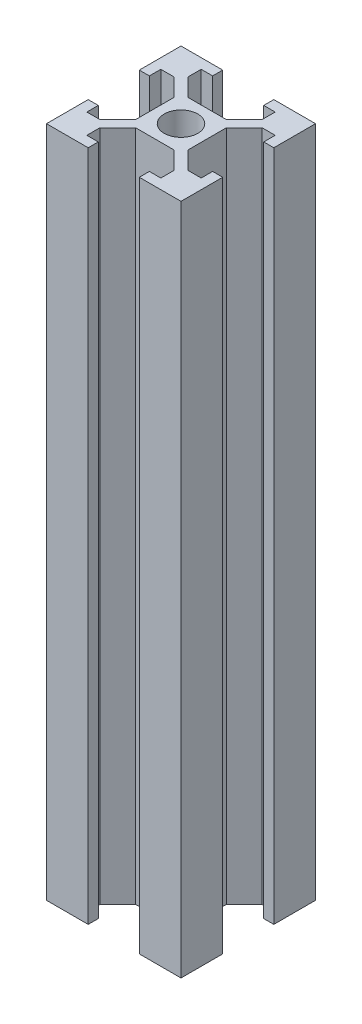
from build123d import *

# Parameters (mm, degrees)
SKETCH_1_W      = 1.5
SKETCH_1_H      = 1.7
SKETCH_1_W_2    = 1.7
SKETCH_1_H_2    = 1.5
SKETCH_1_W_3    = 7.8
SKETCH_1_H_3    = 7.8
SKETCH_1_R      = 2.5
EXTRUDE_1_DEPTH = 100


with BuildPart() as part:
    # 草图1 → 凸台-拉伸1 (new body)
    with BuildSketch(Plane(origin=(0, 0, 0), x_dir=(1, 0, 0), z_dir=(0, 1, 0))):
        Polygon((5.5, 8.5), (5.5, 6.560660172), (5.5, 5.5), (6.560660172, 5.5), (8.5, 5.5), (10, 5.5), (10, 10), (5.5, 10), align=None)
        with Locations((9.25, 4.65)):
            Rectangle(SKETCH_1_W, SKETCH_1_H)
        Polygon((5.5, 6.560660172), (2.839339828, 3.9), (3.9, 3.9), (3.9, 2.839339828), (6.560660172, 5.5), (5.5, 5.5), align=None)
        with Locations((4.65, 9.25)):
            Rectangle(SKETCH_1_W_2, SKETCH_1_H_2)
        Rectangle(SKETCH_1_W_3, SKETCH_1_H_3)
        Circle(SKETCH_1_R, mode=Mode.SUBTRACT)
        with Locations((-4.65, 9.25)):
            Rectangle(SKETCH_1_W_2, SKETCH_1_H_2)
        Polygon((-8.5, 5.5), (-6.560660172, 5.5), (-5.5, 5.5), (-5.5, 6.560660172), (-5.5, 8.5), (-5.5, 10), (-10, 10), (-10, 5.5), align=None)
        with Locations((-9.25, 4.65)):
            Rectangle(SKETCH_1_W, SKETCH_1_H)
        Polygon((-5.5, 5.5), (-6.560660172, 5.5), (-3.9, 2.839339828), (-3.9, 3.9), (-2.839339828, 3.9), (-5.5, 6.560660172), align=None)
        Polygon((-5.5, -5.5), (-6.560660172, -5.5), (-8.5, -5.5), (-10, -5.5), (-10, -10), (-5.5, -10), (-5.5, -8.5), (-5.5, -6.560660172), align=None)
        with Locations((-4.65, -9.25)):
            Rectangle(SKETCH_1_W_2, SKETCH_1_H_2)
        with Locations((-9.25, -4.65)):
            Rectangle(SKETCH_1_W, SKETCH_1_H)
        Polygon((-3.9, -3.9), (-3.9, -2.839339828), (-6.560660172, -5.5), (-5.5, -5.5), (-5.5, -6.560660172), (-2.839339828, -3.9), align=None)
        Polygon((3.9, -3.9), (2.839339828, -3.9), (5.5, -6.560660172), (5.5, -5.5), (6.560660172, -5.5), (3.9, -2.839339828), align=None)
        Polygon((5.5, -5.5), (5.5, -6.560660172), (5.5, -8.5), (5.5, -10), (10, -10), (10, -5.5), (8.5, -5.5), (6.560660172, -5.5), align=None)
        with Locations((9.25, -4.65)):
            Rectangle(SKETCH_1_W, SKETCH_1_H)
        with Locations((4.65, -9.25)):
            Rectangle(SKETCH_1_W_2, SKETCH_1_H_2)
    extrude(amount=EXTRUDE_1_DEPTH)


solid = part.part
